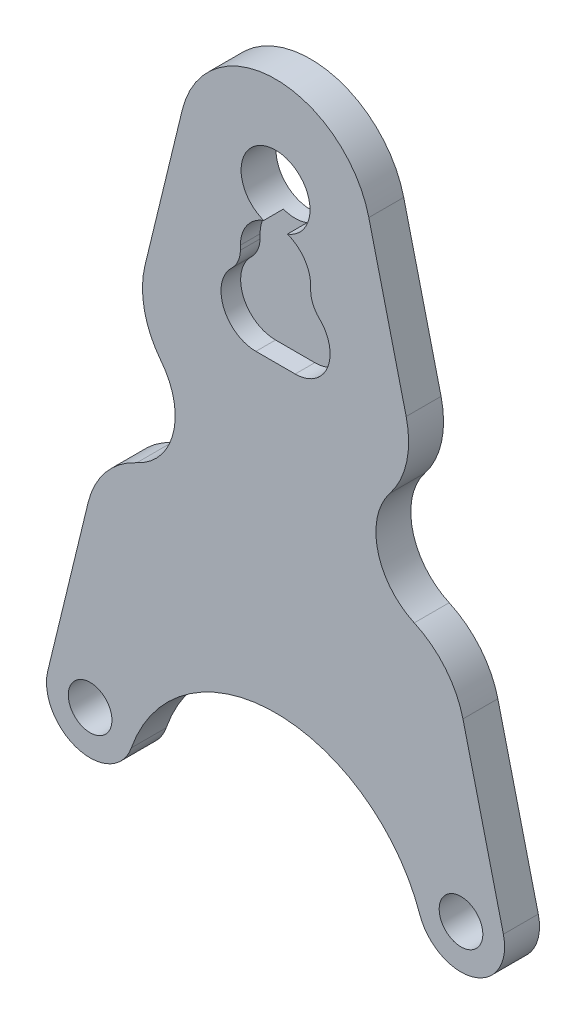
from build123d import *

# Parameters (mm, degrees)
SKETCH_1_R          = 7.9
SKETCH_1_R_2        = 5
EXTRUDE_1_DEPTH     = 8
CUT_EXTRUDE_1_DEPTH = 4.5
SKETCH_3_R          = 15
CUT_EXTRUDE_2_DEPTH = 9
FILLET_1_R          = 20


with BuildPart() as part:
    # Эскиз1 → Бобышка-Вытянуть1 (new body)
    with BuildSketch(Plane.XY):
        with BuildLine():
            Line((-21.377154159, 5.197814933), (-52.216888254, -121.637356848))
            ThreePointArc((-52.216888254, -121.637356848), (-45.327959859, -133.591800823), (-33.055555556, -127.286710991))
            ThreePointArc((-33.055555556, -127.286710991), (0, -103.790199458), (33.055555556, -127.286710991))
            ThreePointArc((33.055555556, -127.286710991), (45.327959859, -133.591800823), (52.216888254, -121.637356848))
            Line((52.216888254, -121.637356848), (21.377154159, 5.197814933))
            ThreePointArc((21.377154159, 5.197814933), (0, 22), (-21.377154159, 5.197814933))
        make_face()
        Circle(SKETCH_1_R, mode=Mode.SUBTRACT)
        with Locations((-42.5, -124)):
            Circle(SKETCH_1_R_2, mode=Mode.SUBTRACT)
        with Locations((42.5, -124)):
            Circle(SKETCH_1_R_2, mode=Mode.SUBTRACT)
    extrude(amount=EXTRUDE_1_DEPTH)

    # Эскиз2 → Вырез-Вытянуть1 (cut)
    with BuildSketch(Plane.XY.offset(8)):
        with BuildLine():
            Line((4.5, -34.3), (-4.5, -34.3))
            ThreePointArc((-4.5, -34.3), (-11.923093689, -29.282897935), (-10.035582708, -20.524420022))
            ThreePointArc((-10.035582708, -20.524420022), (-8.5923829, -18.459875841), (-8.05, -16))
            Line((-8.05, -16), (-8.05, -15))
            ThreePointArc((-8.05, -15), (0, -6.95), (8.05, -15))
            Line((8.05, -15), (8.05, -16))
            ThreePointArc((8.05, -16), (8.5923829, -18.459875841), (10.035582708, -20.524420022))
            ThreePointArc((10.035582708, -20.524420022), (11.923093689, -29.282897935), (4.5, -34.3))
        make_face()
    extrude(amount=-CUT_EXTRUDE_1_DEPTH, mode=Mode.SUBTRACT)

    # Эскиз3 → Вырез-Вытянуть2 (cut, through all)
    with BuildSketch(Plane.XY.offset(8)):
        with Locations((-38, -56.391488719)):
            Circle(SKETCH_3_R)
        with Locations((38, -56.391488719)):
            Circle(SKETCH_3_R)
    extrude(amount=-CUT_EXTRUDE_2_DEPTH, mode=Mode.SUBTRACT)

    # Скругление1
    fillet_1_edges = [part.edges().sort_by_distance(p)[0] for p in [
        (-39.968167407, -71.261805362, 4),
        (-32.920720313, -42.277633191, 4),
        (32.920720313, -42.277633191, 4),
        (39.968167407, -71.261805362, 4),
    ]]
    fillet(fillet_1_edges, radius=FILLET_1_R)


solid = part.part
